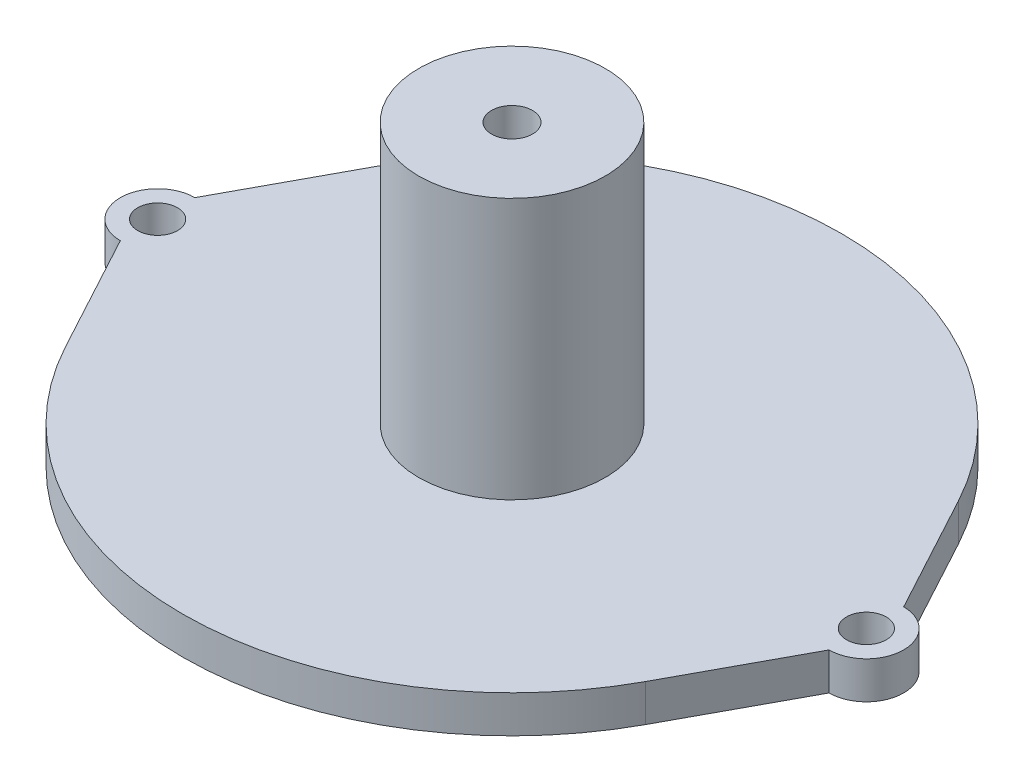
from build123d import *

# Parameters (mm, degrees)
BOSS_EXTRUDE1_DEPTH      = 3
SKETCH2_R                = 7.5
BOSS_EXTRUDE2_DEPTH      = 21
M3_CLEARANCE_HOLE1_D     = 3.2
M3_CLEARANCE_HOLE1_DEPTH = 3
SKETCH5_R                = 1.65
CUT_EXTRUDE1_DEPTH       = 25


with BuildPart() as part:
    # Sketch1 → Boss-Extrude1 (new body)
    with BuildSketch(Plane(origin=(0, 0, 0), x_dir=(1, 0, 0), z_dir=(0, 1, 0))):
        with BuildLine():
            Line((-28.5, 3), (-23.314316453, 12.597327031))
            ThreePointArc((-23.314316453, 12.597327031), (0, 26.5), (23.314316453, 12.597327031))
            Line((23.314316453, 12.597327031), (28.5, 3))
            ThreePointArc((28.5, 3), (31.5, 0), (28.5, -3))
            Line((28.5, -3), (23.314316453, -12.597327031))
            ThreePointArc((23.314316453, -12.597327031), (0, -26.5), (-23.314316453, -12.597327031))
            Line((-23.314316453, -12.597327031), (-28.5, -3))
            ThreePointArc((-28.5, -3), (-31.5, 0), (-28.5, 3))
        make_face()
    extrude(amount=-BOSS_EXTRUDE1_DEPTH)

    # Sketch2 → Boss-Extrude2 (add)
    with BuildSketch(Plane(origin=(0, 0, 0), x_dir=(1, 0, 0), z_dir=(0, 1, 0))):
        Circle(SKETCH2_R)
    extrude(amount=BOSS_EXTRUDE2_DEPTH)

    # M3 Clearance Hole1
    with Locations(Plane(origin=(0, -3, 0), x_dir=(-1, 0, 0), z_dir=(0, -1, 0))):
        with Locations((-28.5, 0), (28.5, 0)):
            Hole(M3_CLEARANCE_HOLE1_D / 2, depth=M3_CLEARANCE_HOLE1_DEPTH)

    # Sketch5 → Cut-Extrude1 (cut, through all)
    with BuildSketch(Plane(origin=(0, 21, 0), x_dir=(1, 0, 0), z_dir=(0, 1, 0))):
        Circle(SKETCH5_R)
    extrude(amount=-CUT_EXTRUDE1_DEPTH, mode=Mode.SUBTRACT)


solid = part.part
